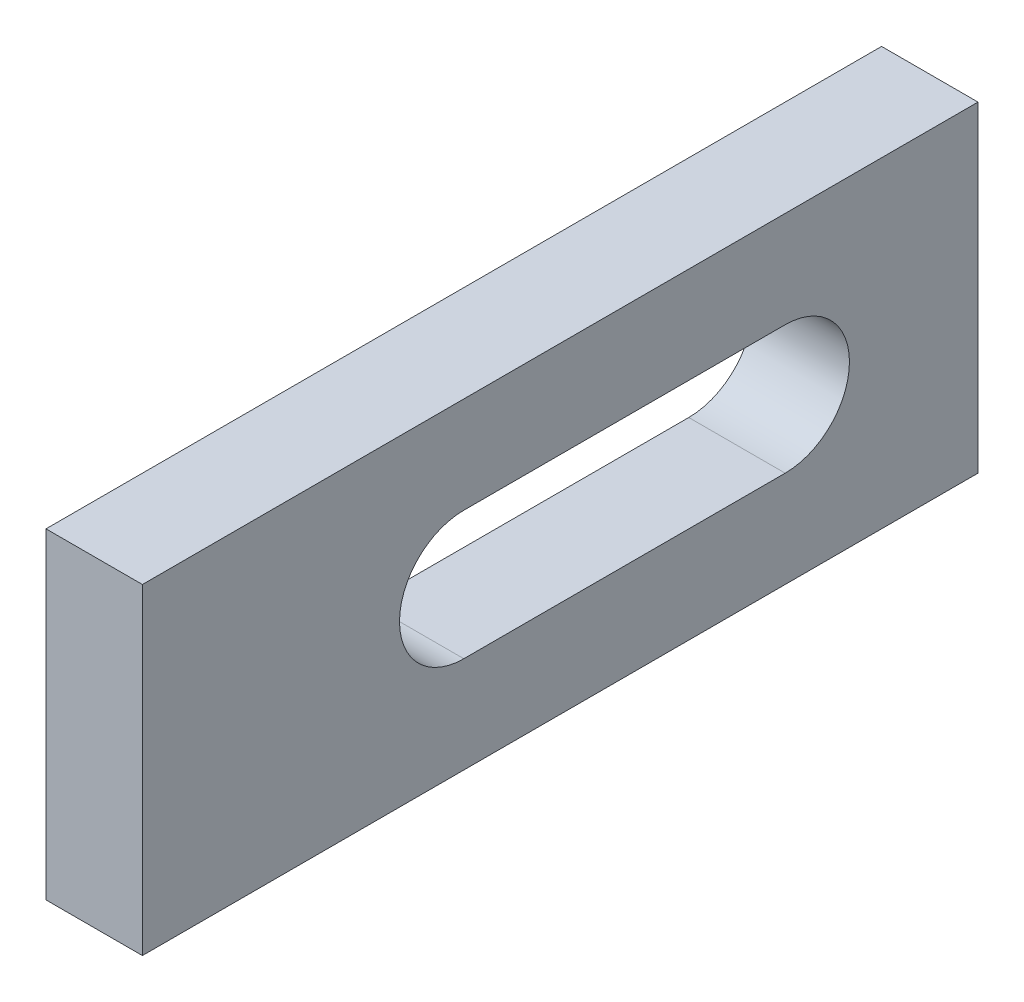
from build123d import *

# Parameters (mm, degrees)
ESQUISSE1_W             = 15
ESQUISSE1_H             = 50
BOSS_EXTRU_1_DEPTH      = 65
ENL_V_MAT_EXTRU_1_DEPTH = 110


with BuildPart() as part:
    # Esquisse1 → Boss.-Extru.1 (new body, symmetric)
    with BuildSketch(Plane.XY):
        Rectangle(ESQUISSE1_W, ESQUISSE1_H)
    extrude(amount=BOSS_EXTRU_1_DEPTH, both=True)

    # Esquisse2 → Enlèv. mat.-Extru.1 (cut)
    with BuildSketch(Plane(origin=(7.5, 0, 0), x_dir=(0, 0, -1), z_dir=(1, 0, 0))):
        with BuildLine():
            Line((-15, 10), (35, 10))
            ThreePointArc((35, 10), (45, 0), (35, -10))
            Line((35, -10), (-15, -10))
            ThreePointArc((-15, -10), (-25, 0), (-15, 10))
        make_face()
    extrude(amount=-ENL_V_MAT_EXTRU_1_DEPTH, mode=Mode.SUBTRACT)


solid = part.part
